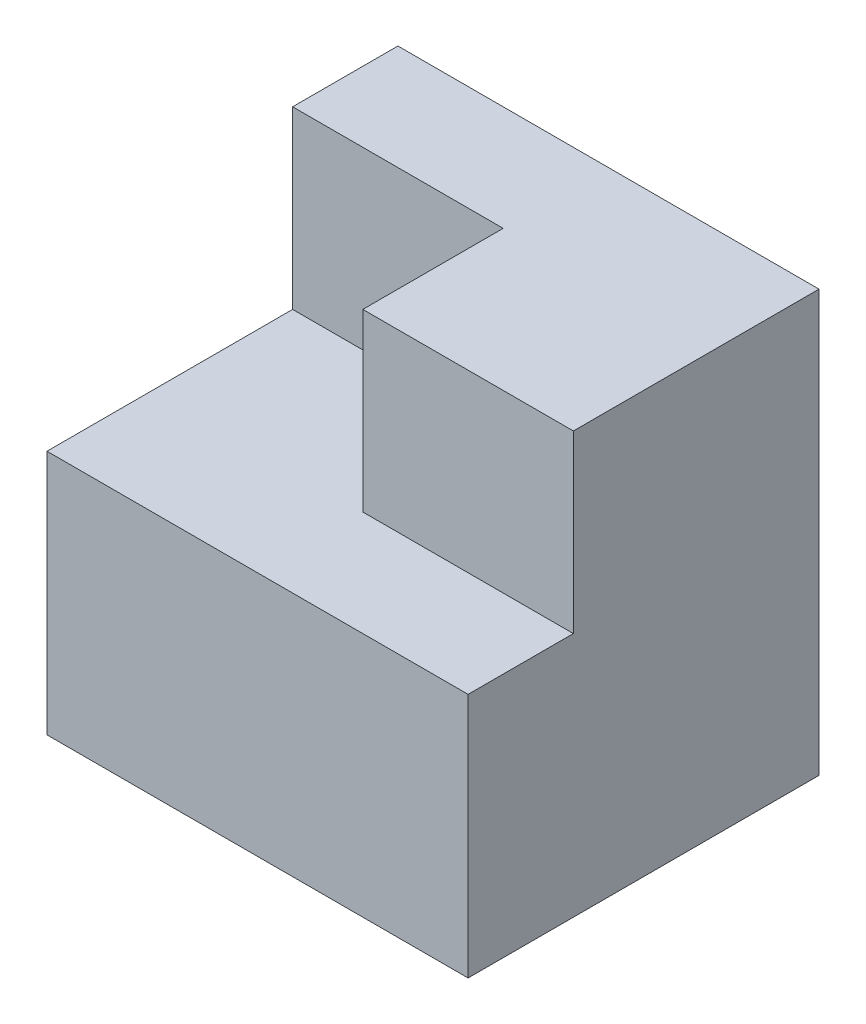
from build123d import *

# Parameters (mm, degrees)
SKETCH1_W           = 6
SKETCH1_H           = 5
BOSS_EXTRUDE1_DEPTH = 6
CUT_EXTRUDE1_DEPTH  = 2.5


with BuildPart() as part:
    # Sketch1 → Boss-Extrude1 (new body)
    with BuildSketch(Plane(origin=(0, 0, 0), x_dir=(1, 0, 0), z_dir=(0, 1, 0))):
        Rectangle(SKETCH1_W, SKETCH1_H)
    extrude(amount=BOSS_EXTRUDE1_DEPTH)

    # Sketch2 → Cut-Extrude1 (cut)
    with BuildSketch(Plane(origin=(0, 6, 0), x_dir=(1, 0, 0), z_dir=(0, 1, 0))):
        Polygon((3, -1), (0, -1), (0, 1), (-3, 1), (-3, -2.5), (3, -2.5), align=None)
    extrude(amount=-CUT_EXTRUDE1_DEPTH, mode=Mode.SUBTRACT)


solid = part.part
